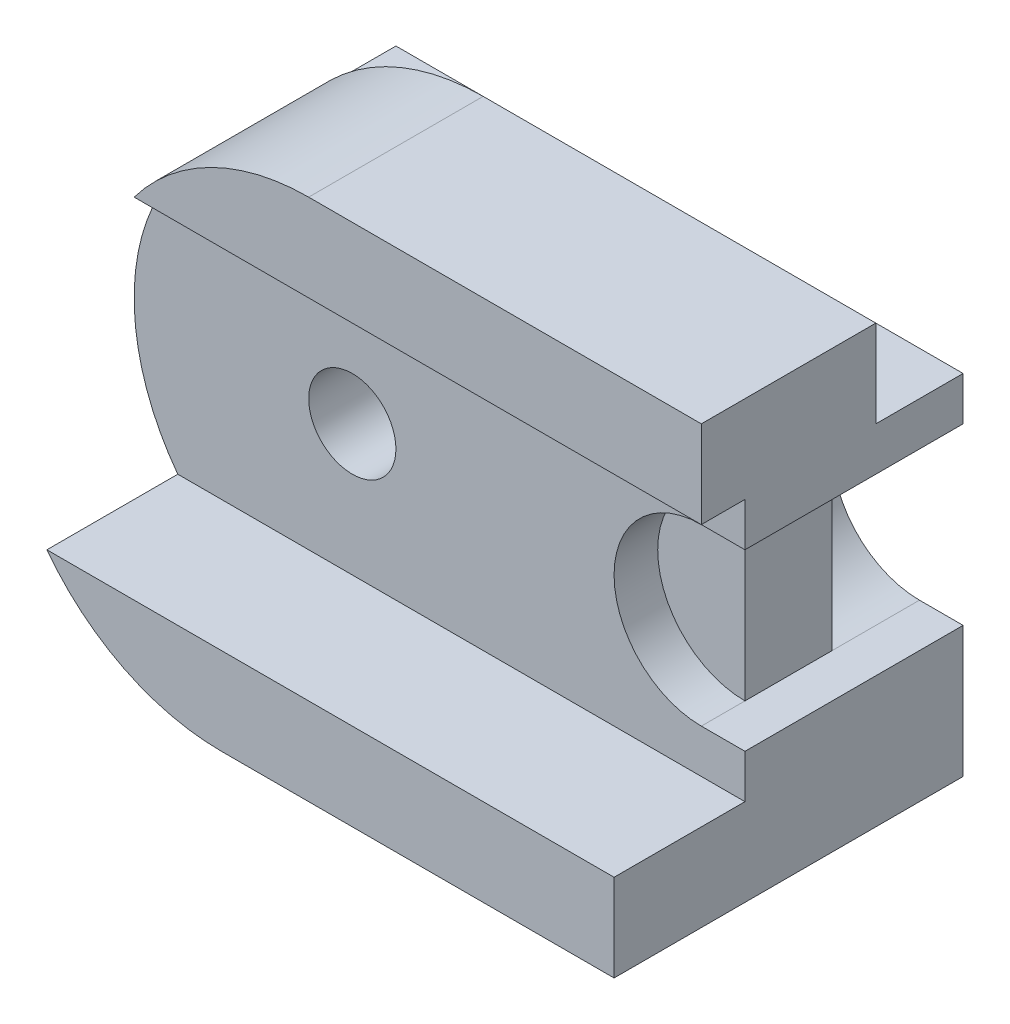
from build123d import *

# Parameters (mm, degrees)
BOSS_EXTRUDE2_DEPTH = 80
SKETCH8_W           = 20
SKETCH8_H           = 20
CUT_EXTRUDE5_DEPTH  = 205
SKETCH9_W           = 30
SKETCH9_H           = 60
CUT_EXTRUDE6_DEPTH  = 205
SKETCH10_W          = 20
SKETCH10_H          = 20
CUT_EXTRUDE8_DEPTH  = 150
SKETCH13_R          = 10
CUT_EXTRUDE9_DEPTH  = 150
BOSS_EXTRUDE5_DEPTH = 40
CUT_EXTRUDE10_DEPTH = 20
CUT_EXTRUDE15_DEPTH = 20
SKETCH18_W          = 10
SKETCH18_H          = 20
CUT_EXTRUDE16_DEPTH = 0.0001


with BuildPart() as part:
    # Sketch1 → Boss-Extrude2 (new body)
    with BuildSketch(Plane.XY):
        with BuildLine():
            ThreePointArc((80, 20), (60, 0), (80, -20))
            Line((80, -20), (90, -20))
            Line((90, -20), (90, -50))
            Line((90, -50), (0, -50))
            ThreePointArc((0, -50), (-50, 0), (0, 50))
            Line((0, 50), (90, 50))
            Line((90, 50), (90, 20))
            Line((90, 20), (80, 20))
        make_face()
    extrude(amount=BOSS_EXTRUDE2_DEPTH)

    # Sketch8 → Cut-Extrude5 (cut)
    with BuildSketch(Plane(origin=(90, 0, 0), x_dir=(0, 0, -1), z_dir=(1, 0, 0))):
        with Locations((-10, 40)):
            Rectangle(SKETCH8_W, SKETCH8_H)
    extrude(amount=-CUT_EXTRUDE5_DEPTH, mode=Mode.SUBTRACT)

    # Sketch9 → Cut-Extrude6 (cut)
    with BuildSketch(Plane(origin=(-50, 0, 0), x_dir=(0, 0, -1), z_dir=(1, 0, 0))):
        with Locations((-65, 0)):
            Rectangle(SKETCH9_W, SKETCH9_H)
    extrude(amount=CUT_EXTRUDE6_DEPTH, mode=Mode.SUBTRACT)

    # Sketch10 → Cut-Extrude8 (cut)
    with BuildSketch(Plane(origin=(90, 0, 0), x_dir=(0, 0, -1), z_dir=(1, 0, 0))):
        with Locations((-70, 40)):
            Rectangle(SKETCH10_W, SKETCH10_H)
    extrude(amount=-CUT_EXTRUDE8_DEPTH, mode=Mode.SUBTRACT)

    # Sketch13 → Cut-Extrude9 (cut)
    with BuildSketch(Plane.XY.offset(50)):
        Circle(SKETCH13_R)
    extrude(amount=-CUT_EXTRUDE9_DEPTH, mode=Mode.SUBTRACT)

    # Sketch14 → Boss-Extrude5 (add)
    with BuildSketch(Plane(origin=(0, 0, 0), x_dir=(-1, 0, 0), z_dir=(0, 0, -1))):
        with BuildLine():
            Line((-80, 20), (-80, -20))
            ThreePointArc((-80, -20), (-60, 0), (-80, 20))
        make_face()
    extrude(amount=-BOSS_EXTRUDE5_DEPTH)

    # Sketch15 → Cut-Extrude10 (cut)
    with BuildSketch(Plane(origin=(0, 0, 0), x_dir=(-1, 0, 0), z_dir=(0, 0, -1))):
        with BuildLine():
            Line((-80, 20), (-80, -20))
            ThreePointArc((-80, -20), (-60, 0), (-80, 20))
        make_face()
    extrude(amount=-CUT_EXTRUDE10_DEPTH, mode=Mode.SUBTRACT)

    # Sketch16 → Cut-Extrude15 (cut)
    with BuildSketch(Plane(origin=(0, 0, 0), x_dir=(-1, 0, 0), z_dir=(0, 0, -1))):
        with BuildLine():
            Line((-10, 0), (-49.99900001, 0))
            ThreePointArc((-49.99900001, 0), (-35.354985511, -35.354278404), (-0.001, -49.999))
            Line((-0.001, -49.999), (-0.001, -9.99999995))
            ThreePointArc((-0.001, -9.99999995), (-7.071421356, -7.07071425), (-10, 0))
        make_face()
        with BuildLine():
            Line((-0.001, 30), (-40, 30))
            ThreePointArc((-40, 30), (-47.434164903, 15.811388301), (-50, 0))
            Line((-50, 0), (-49.99900001, 0))
            Line((-49.99900001, 0), (-10, 0))
            ThreePointArc((-10, 0), (-7.071421356, 7.07071425), (-0.001, 9.99999995))
            Line((-0.001, 10), (-0.001, 30))
        make_face()
    extrude(amount=-CUT_EXTRUDE15_DEPTH, mode=Mode.SUBTRACT)

    # Sketch18 → Cut-Extrude16 (cut)
    with BuildSketch(Plane(origin=(0, -50, 0), x_dir=(-1, 0, 0), z_dir=(0, -1, 0))):
        with Locations((-5, -10)):
            Rectangle(SKETCH18_W, SKETCH18_H)
    extrude(amount=-CUT_EXTRUDE16_DEPTH, mode=Mode.SUBTRACT)


solid = part.part
